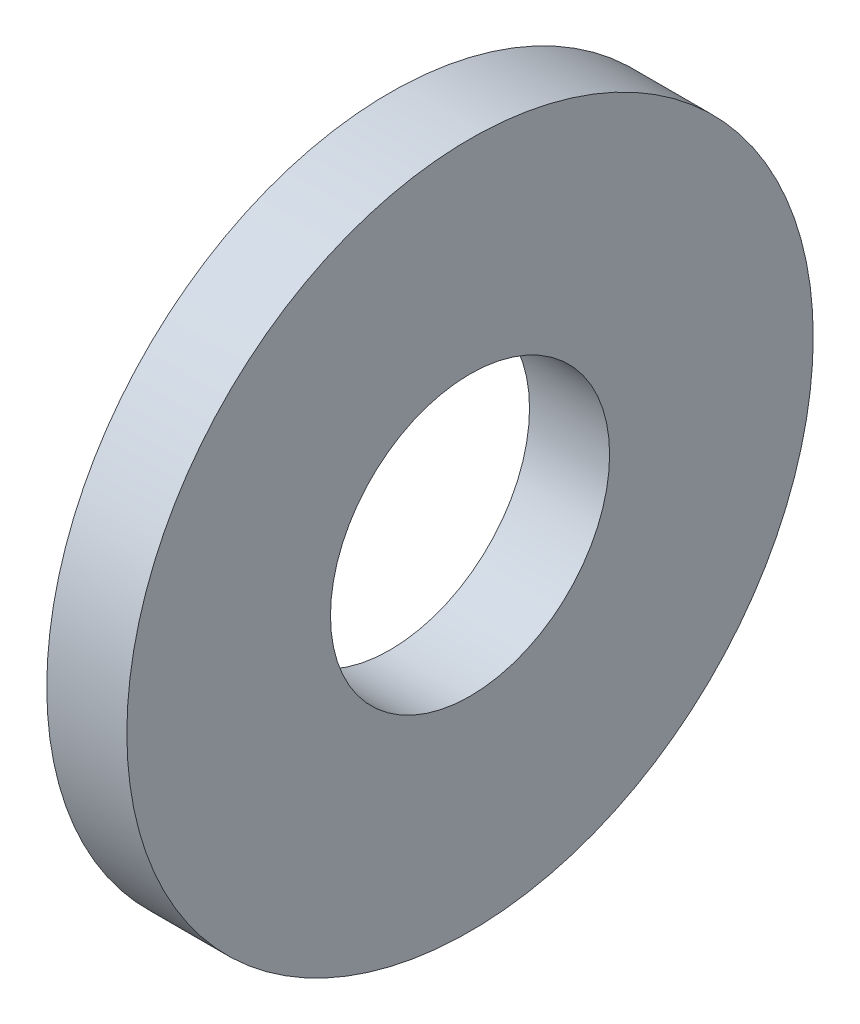
from build123d import *

# Parameters (mm, degrees)
SKETCH1_W = 1.4
SKETCH1_H = 3.56


with BuildPart() as part:
    # Sketch1 → Base-Revolve (revolve)
    with BuildSketch(Plane.XY):
        with Locations((-0.7, 4.22)):
            Rectangle(SKETCH1_W, SKETCH1_H)
    revolve(axis=Axis((-34.925, 0, 0), (1, 0, 0)))


solid = part.part
